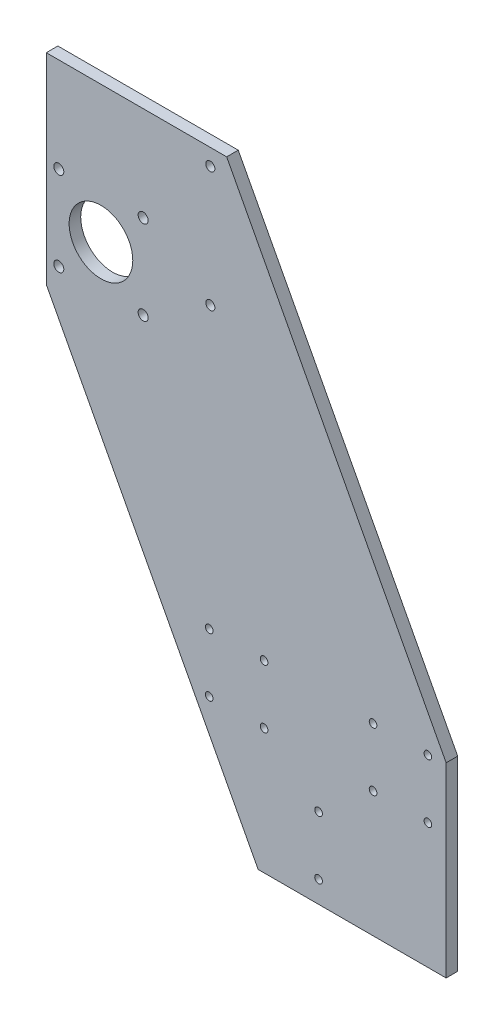
from build123d import *

# Parameters (mm, degrees)
CROQUIS1_R              = 2.1
SALIENTE_EXTRUIR1_DEPTH = 6.35
CROQUIS2_R              = 2.75
CROQUIS2_R_2            = 17.4625
CROQUIS2_R_3            = 2.5
CORTAR_EXTRUIR1_DEPTH   = 12.7


with BuildPart() as part:
    # Croquis1 → Saliente-Extruir1 (new body)
    with BuildSketch(Plane.XY):
        Polygon((0, 0), (0, 82.389877484), (-120.421799317, 310.14248627), (-219.400809699, 310.14248627), (-219.400809699, 200), (-103.153458954, -19.85751373), (0, -19.85751373), align=None)
        with Locations((-40.1, 81.05)):
            Circle(CROQUIS1_R, mode=Mode.SUBTRACT)
        with Locations((-10, 81.05)):
            Circle(CROQUIS1_R, mode=Mode.SUBTRACT)
        with Locations((-10, 48.95)):
            Circle(CROQUIS1_R, mode=Mode.SUBTRACT)
        with Locations((-40.1, 48.95)):
            Circle(CROQUIS1_R, mode=Mode.SUBTRACT)
        with Locations((-130, 81.05)):
            Circle(CROQUIS1_R, mode=Mode.SUBTRACT)
        with Locations((-99.9, 81.05)):
            Circle(CROQUIS1_R, mode=Mode.SUBTRACT)
        with Locations((-99.9, 48.95)):
            Circle(CROQUIS1_R, mode=Mode.SUBTRACT)
        with Locations((-130, 48.95)):
            Circle(CROQUIS1_R, mode=Mode.SUBTRACT)
        with Locations((-70, 24.15)):
            Circle(CROQUIS1_R, mode=Mode.SUBTRACT)
        with Locations((-70, -7.95)):
            Circle(CROQUIS1_R, mode=Mode.SUBTRACT)
    extrude(amount=SALIENTE_EXTRUIR1_DEPTH)

    # Croquis2 → Cortar-Extruir1 (cut)
    with BuildSketch(Plane.XY.offset(6.35)):
        with Locations((-212.545809699, 258.28748627)):
            Circle(CROQUIS2_R)
        with Locations((-212.545809699, 211.99748627)):
            Circle(CROQUIS2_R)
        with Locations((-166.255809699, 211.99748627)):
            Circle(CROQUIS2_R)
        with Locations((-166.255809699, 258.28748627)):
            Circle(CROQUIS2_R)
        with Locations((-189.400809699, 235.14248627)):
            Circle(CROQUIS2_R_2)
        with Locations((-129.400809699, 235.14248627)):
            Circle(CROQUIS2_R_3)
        with Locations((-129.400809699, 301.14248627)):
            Circle(CROQUIS2_R_3)
    extrude(amount=-CORTAR_EXTRUIR1_DEPTH, mode=Mode.SUBTRACT)


solid = part.part
